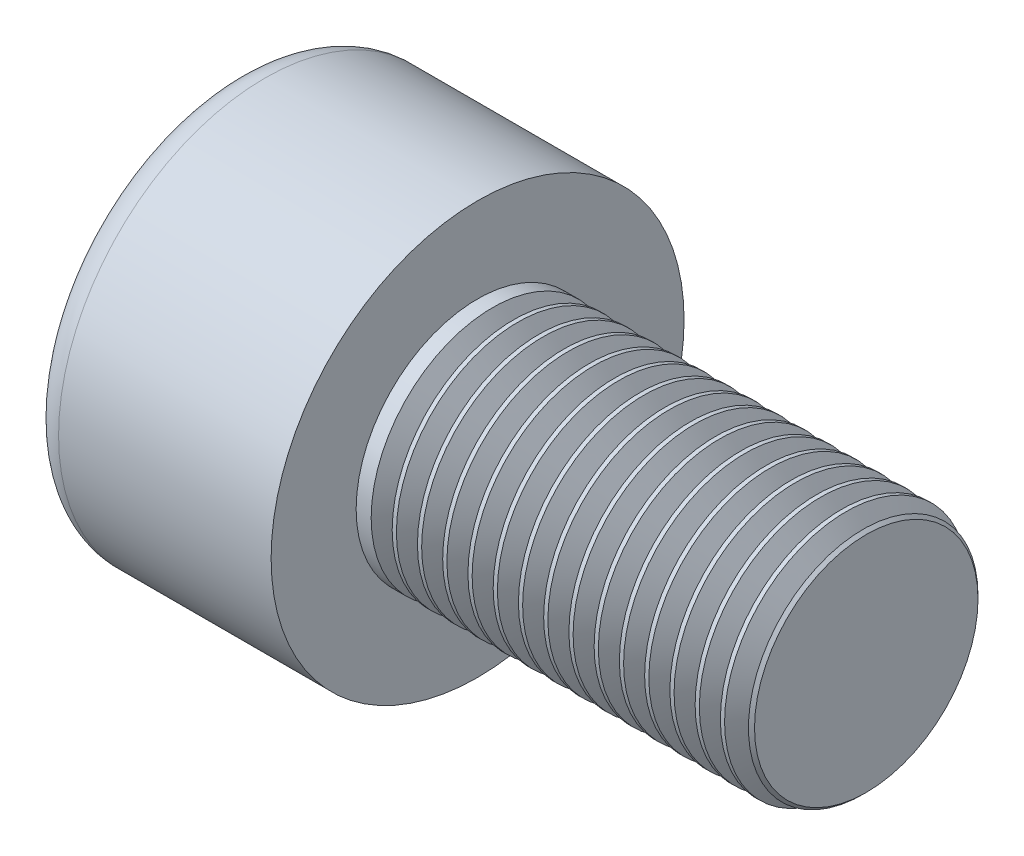
from build123d import *

# Parameters (mm, degrees)
SKETCH1_R           = 4.25
BASEHEAD_DEPTH      = 5
SKETCH2_R           = 2.5
BASEBODY_DEPTH      = 8
HEXAGONSOCKET_DEPTH = 2.5
TOPFILLET_R         = 0.625
CHAMFER1_SIZE       = 0.2
LPATTERN10_COUNT    = 15
LPATTERN10_PITCH    = 0.5196


with BuildPart() as part:
    # Sketch1 → BaseHead (new body)
    with BuildSketch(Plane(origin=(0, 0, 0), x_dir=(0, 0, -1), z_dir=(1, 0, 0))):
        Circle(SKETCH1_R)
    extrude(amount=BASEHEAD_DEPTH)

    # Sketch2 → BaseBody (add)
    with BuildSketch(Plane(origin=(5, 0, 0), x_dir=(0, 0, -1), z_dir=(1, 0, 0))):
        Circle(SKETCH2_R)
    extrude(amount=BASEBODY_DEPTH)

    # Sketch3 → HexagonSocket (cut)
    with BuildSketch(Plane(origin=(0, 0, 0), x_dir=(0, 0, -1), z_dir=(1, 0, 0))):
        Polygon((2.309401077, 0), (1.154700538, 2), (-1.154700538, 2), (-2.309401077, 0), (-1.154700538, -2), (1.154700538, -2), align=None)
    extrude(amount=HEXAGONSOCKET_DEPTH, mode=Mode.SUBTRACT)

    # Sketch4 → Cut-Revolve1 (revolve, cut)
    with BuildSketch(Plane(origin=(-4.19613823, 0.75, 0), x_dir=(-1, 0, 0), z_dir=(0, 0, 1))):
        Polygon((-6.69613823, 2.75), (-7.850838768, 0.75), (-6.69613823, 0.75), align=None)
    revolve(axis=Axis((0.838992387, 0, 0), (-1, 0, 0)), mode=Mode.SUBTRACT)

    # TopFillet
    topfillet_edges = [part.edges().sort_by_distance(p)[0] for p in [
        (0, 0, 4.25),
    ]]
    fillet(topfillet_edges, radius=TOPFILLET_R)

    # Chamfer1
    chamfer1_edges = [part.edges().sort_by_distance(p)[0] for p in [
        (13, 0, 2.5),
    ]]
    chamfer(chamfer1_edges, length=CHAMFER1_SIZE)

    # Sketch5 → Cut-Revolve10 (revolve, cut)
    with BuildSketch(Plane.XY):
        Polygon((12.8, 2.125011), (13.0165, 2.5), (13.0165, 2.933), (12.5835, 2.933), (12.5835, 2.5), align=None)
    cut_revolve10 = revolve(axis=Axis((0, 0, 0), (1, 0, 0)), mode=Mode.SUBTRACT)

    # LPattern10: Cut-Revolve10 ×15
    with Locations(*[(-i * LPATTERN10_PITCH, 0, 0) for i in range(1, LPATTERN10_COUNT)]):
        add(cut_revolve10, mode=Mode.SUBTRACT)


solid = part.part
